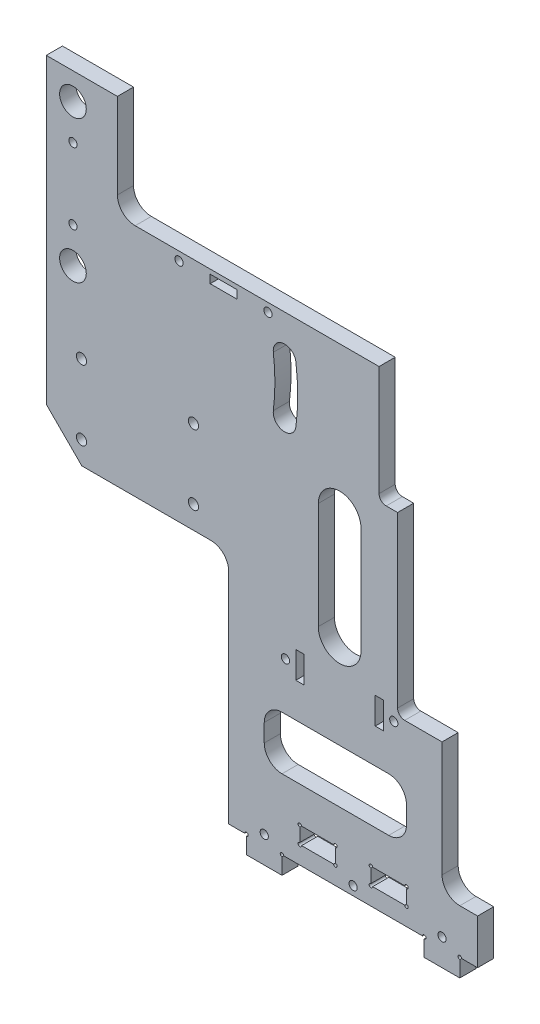
from build123d import *

# Parameters (mm, degrees)
SKETCH1_W                        = 12.7
SKETCH1_H                        = 6.0198
BOSS_EXTRUDE1_DEPTH              = 5.7658
SKETCH13_R                       = 0.635
CUT_EXTRUDE2_DEPTH               = 5.7658
CHAMFER1_SIZE                    = 50.8
F_4_CLEARANCE_HOLE1_D            = 2.9464
F_4_CLEARANCE_HOLE1_DEPTH        = 6.35
F_4_CLEARANCE_HOLE1_TIP          = 0.885187864
F_3_8_0_375_DIAMETER_HOLE1_D     = 9.525
F_3_8_0_375_DIAMETER_HOLE1_DEPTH = 6.35
F_3_8_0_375_DIAMETER_HOLE1_TIP   = 2.861598698
CUT_EXTRUDE3_REACH               = 234.708
FILLET3_R                        = 6.35
CUT_EXTRUDE4_REACH               = 234.708
CUT_EXTRUDE5_REACH               = 234.708
SKETCH26_W                       = 2.9591
SKETCH26_H                       = 9.525
CUT_EXTRUDE6_REACH               = 234.708
SKETCH29_W                       = 65.024
SKETCH29_H                       = 36.83
FILLET5_R                        = 6.35
SKETCH30_W                       = 65.151
SKETCH30_H                       = 50.8
BOSS_EXTRUDE2_DEPTH              = 5.7658
FILLET6_R                        = 6.35
CUT_EXTRUDE9_REACH               = 234.708
SKETCH32_W                       = 9.525
SKETCH32_H                       = 2.9591
F_6_CLEARANCE_HOLE1_D            = 3.6576
F_6_CLEARANCE_HOLE1_DEPTH        = 5.842
F_6_CLEARANCE_HOLE1_TIP          = 1.0988539
CUT_EXTRUDE10_REACH              = 234.708
CHAMFER3_SIZE                    = 12.7
CUT_EXTRUDE11_START              = -5.7658
CUT_EXTRUDE11_DEPTH              = 5.7658
CUT_EXTRUDE12_REACH              = 234.708
SKETCH36_W                       = 57.277
SKETCH36_H                       = 36.83
FILLET7_R                        = 2.54
FILLET8_R                        = 6.35
CUT_EXTRUDE13_REACH              = 234.708
SKETCH37_W                       = 9.525
SKETCH37_H                       = 2.9591
F_4_CLEARANCE_HOLE2_D            = 2.9464
F_4_CLEARANCE_HOLE2_DEPTH        = 5.7658
SKETCH38_W                       = 50.8
SKETCH38_H                       = 19.05
CUT_EXTRUDE14_DEPTH              = 233.70795425
FILLET9_R                        = 6.35


with BuildPart() as part:
    # Sketch1 → Boss-Extrude1 (new body)
    with BuildSketch(Plane.XY):
        Polygon((-25.4, 0), (25.4, 0), (25.4, -6.35), (38.1, -6.35), (38.1, 0), (44.45, 0), (44.45, 205.2008), (-109.601, 205.2008), (-109.601, 135.3508), (-44.45, 135.3508), (-44.45, 0), (-38.1, 0), (-38.1, -6.35), (-25.4, -6.35), align=None)
        with Locations((12.7, 9.3599)):
            Rectangle(SKETCH1_W, SKETCH1_H, mode=Mode.SUBTRACT)
        with Locations((-12.7, 9.3599)):
            Rectangle(SKETCH1_W, SKETCH1_H, mode=Mode.SUBTRACT)
    extrude(amount=BOSS_EXTRUDE1_DEPTH)

    # Sketch13 → Cut-Extrude2 (cut)
    with BuildSketch(Plane.XY):
        with Locations((-19.05, 12.3698)):
            Circle(SKETCH13_R)
    cut_extrude2 = extrude(amount=CUT_EXTRUDE2_DEPTH, mode=Mode.SUBTRACT)

    # Sketch-Pattern1: Cut-Extrude2 at 11 more places
    with Locations((12.7, 0, 0), (12.7, -6.0198, 0), (0, -6.0198, 0), (25.4, 0, 0), (38.1, 0, 0), (38.1, -6.0198, 0), (25.4, -6.0198, 0), (57.15, -12.3698, 0), (44.45, -12.3698, 0), (-6.35, -12.3698, 0), (-19.05, -12.3698, 0)):
        add(cut_extrude2, mode=Mode.SUBTRACT)

    # Chamfer1
    chamfer1_edges = [part.edges().sort_by_distance(p)[0] for p in [
        (44.45, 205.2008, 2.8829),
    ]]
    chamfer(chamfer1_edges, length=CHAMFER1_SIZE)

    # #4 Clearance Hole1
    with Locations(Plane.XY.offset(5.7658)):
        with Locations((-31.75, 3.175), (31.75, 3.175), (0, 3.175)):
            Hole(F_4_CLEARANCE_HOLE1_D / 2, depth=F_4_CLEARANCE_HOLE1_DEPTH)
            with Locations((0, 0, -(F_4_CLEARANCE_HOLE1_DEPTH + F_4_CLEARANCE_HOLE1_TIP / 2))):  # 118° drill point
                Cone(0, F_4_CLEARANCE_HOLE1_D / 2, F_4_CLEARANCE_HOLE1_TIP, mode=Mode.SUBTRACT)

    # 3/8 (0.375) Diameter Hole1
    with Locations(Plane.XY.offset(5.7658)):
        with Locations((-100.076, 144.8758), (-100.076, 195.6758)):
            Hole(F_3_8_0_375_DIAMETER_HOLE1_D / 2, depth=F_3_8_0_375_DIAMETER_HOLE1_DEPTH)
            with Locations((0, 0, -(F_3_8_0_375_DIAMETER_HOLE1_DEPTH + F_3_8_0_375_DIAMETER_HOLE1_TIP / 2))):  # 118° drill point
                Cone(0, F_3_8_0_375_DIAMETER_HOLE1_D / 2, F_3_8_0_375_DIAMETER_HOLE1_TIP, mode=Mode.SUBTRACT)

    # Sketch24 → Cut-Extrude3 (cut, up to next)
    with BuildSketch(Plane.XY.offset(5.7658), mode=Mode.PRIVATE) as cut_extrude3_sk1:
        Polygon((31.75, 167.1008), (31.75, 16.002), (44.45, 16.002), (44.45, 154.4008), align=None)
    cut_extrude3_tool1 = extrude(cut_extrude3_sk1.sketch, amount=-CUT_EXTRUDE3_REACH, mode=Mode.PRIVATE) & part.part
    add(cut_extrude3_tool1.solids().sort_by_distance((38.007144, 88.422828, 5.7658))[0], mode=Mode.SUBTRACT)

    # Fillet3
    fillet3_edges = [part.edges().sort_by_distance(p)[0] for p in [
        (31.75, 16.002, 2.8829),
    ]]
    fillet(fillet3_edges, radius=FILLET3_R)

    # Sketch25 → Cut-Extrude4 (cut, up to next)
    with BuildSketch(Plane.XY.offset(5.7658), mode=Mode.PRIVATE) as cut_extrude4_sk1:
        with BuildLine():
            ThreePointArc((-20.441531288, 134.8428), (-19.812, 144.8758), (-20.441531288, 154.9088))
            ThreePointArc((-20.441531288, 154.9088), (-24.981656286, 158.432924998), (-28.505781284, 153.8928))
            ThreePointArc((-28.505781284, 153.8928), (-27.94, 144.8758), (-28.505781284, 135.8588))
            ThreePointArc((-28.505781284, 135.8588), (-24.981656286, 131.318675002), (-20.441531288, 134.8428))
        make_face()
    cut_extrude4_tool1 = extrude(cut_extrude4_sk1.sketch, amount=-CUT_EXTRUDE4_REACH, mode=Mode.PRIVATE) & part.part
    # Sketch25 → Cut-Extrude4 (cut, up to next)
    with BuildSketch(Plane.XY.offset(5.7658), mode=Mode.PRIVATE) as cut_extrude4_sk2:
        with BuildLine():
            ThreePointArc((17.359640569, 130.0803), (18.288, 144.8758), (17.359640569, 159.6713))
            ThreePointArc((17.359640569, 159.6713), (12.819515571, 163.195424998), (9.295390572, 158.6553))
            ThreePointArc((9.295390572, 158.6553), (10.16, 144.8758), (9.295390572, 131.0963))
            ThreePointArc((9.295390572, 131.0963), (12.819515571, 126.556175002), (17.359640569, 130.0803))
        make_face()
    cut_extrude4_tool2 = extrude(cut_extrude4_sk2.sketch, amount=-CUT_EXTRUDE4_REACH, mode=Mode.PRIVATE) & part.part
    add(cut_extrude4_tool1.solids().sort_by_distance((-24.175106, 144.8758, 5.7658))[0], mode=Mode.SUBTRACT)
    add(cut_extrude4_tool2.solids().sort_by_distance((13.816141, 144.8758, 5.7658))[0], mode=Mode.SUBTRACT)

    # Sketch26 → Cut-Extrude5 (cut, up to next)
    with BuildSketch(Plane.XY.offset(5.7658), mode=Mode.PRIVATE) as cut_extrude5_sk1:
        with Locations((9.35355, 61.214)):
            Rectangle(SKETCH26_W, SKETCH26_H)
    cut_extrude5_tool1 = extrude(cut_extrude5_sk1.sketch, amount=-CUT_EXTRUDE5_REACH, mode=Mode.PRIVATE) & part.part
    # Sketch26 → Cut-Extrude5 (cut, up to next)
    with BuildSketch(Plane.XY.offset(5.7658), mode=Mode.PRIVATE) as cut_extrude5_sk2:
        with Locations((-19.00555, 61.214)):
            Rectangle(SKETCH26_W, SKETCH26_H)
    cut_extrude5_tool2 = extrude(cut_extrude5_sk2.sketch, amount=-CUT_EXTRUDE5_REACH, mode=Mode.PRIVATE) & part.part
    add(cut_extrude5_tool1.solids().sort_by_distance((9.35355, 61.214, 5.7658))[0], mode=Mode.SUBTRACT)
    add(cut_extrude5_tool2.solids().sort_by_distance((-19.00555, 61.214, 5.7658))[0], mode=Mode.SUBTRACT)

    # Sketch29 → Cut-Extrude6 (cut, up to next)
    with BuildSketch(Plane.XY.offset(5.7658), mode=Mode.PRIVATE) as cut_extrude6_sk1:
        with Locations((-0.762, 186.7858)):
            Rectangle(SKETCH29_W, SKETCH29_H)
    cut_extrude6_tool1 = extrude(cut_extrude6_sk1.sketch, amount=-CUT_EXTRUDE6_REACH, mode=Mode.PRIVATE) & part.part
    add(cut_extrude6_tool1.solids().sort_by_distance((-0.762, 186.7858, 5.7658))[0], mode=Mode.SUBTRACT)

    # Fillet5
    fillet5_edges = [part.edges().sort_by_distance(p)[0] for p in [
        (-33.274, 168.3708, 2.8829),
    ]]
    fillet(fillet5_edges, radius=FILLET5_R)

    # Sketch30 → Boss-Extrude2 (add)
    with BuildSketch(Plane.XY.offset(5.7658)):
        with Locations((-77.0255, 109.9508)):
            Rectangle(SKETCH30_W, SKETCH30_H)
    extrude(amount=-BOSS_EXTRUDE2_DEPTH)

    # Fillet6
    fillet6_edges = [part.edges().sort_by_distance(p)[0] for p in [
        (-44.45, 84.5508, 2.8829),
    ]]
    fillet(fillet6_edges, radius=FILLET6_R)

    # Sketch32 → Cut-Extrude9 (cut, up to next)
    with BuildSketch(Plane.XY.offset(5.7658), mode=Mode.PRIVATE) as cut_extrude9_sk1:
        with Locations((20.6375, 166.0975)):
            Rectangle(SKETCH32_W, SKETCH32_H)
    cut_extrude9_tool1 = extrude(cut_extrude9_sk1.sketch, amount=-CUT_EXTRUDE9_REACH, mode=Mode.PRIVATE) & part.part
    add(cut_extrude9_tool1.solids().sort_by_distance((20.6375, 166.0975, 5.7658))[0], mode=Mode.SUBTRACT)

    # #6 Clearance Hole1
    with Locations(Plane.XY.offset(5.7658)):
        with Locations((-97.0255, 117.65), (-57.0255, 117.65), (-97.0255, 92.65), (-57.0255, 92.65)):
            Hole(F_6_CLEARANCE_HOLE1_D / 2, depth=F_6_CLEARANCE_HOLE1_DEPTH)
            with Locations((0, 0, -(F_6_CLEARANCE_HOLE1_DEPTH + F_6_CLEARANCE_HOLE1_TIP / 2))):  # 118° drill point
                Cone(0, F_6_CLEARANCE_HOLE1_D / 2, F_6_CLEARANCE_HOLE1_TIP, mode=Mode.SUBTRACT)

    # Sketch31 → Cut-Extrude10 (cut, up to next)
    with BuildSketch(Plane.XY.offset(5.7658), mode=Mode.PRIVATE) as cut_extrude10_sk1:
        with BuildLine():
            Line((-12.446, 77.0763), (-12.446, 115.1763))
            ThreePointArc((-12.446, 115.1763), (-4.826, 122.7963), (2.794, 115.1763))
            Line((2.794, 115.1763), (2.794, 77.0763))
            ThreePointArc((2.794, 77.0763), (-4.826, 69.4563), (-12.446, 77.0763))
        make_face()
    cut_extrude10_tool1 = extrude(cut_extrude10_sk1.sketch, amount=-CUT_EXTRUDE10_REACH, mode=Mode.PRIVATE) & part.part
    add(cut_extrude10_tool1.solids().sort_by_distance((-4.826, 96.1263, 5.7658))[0], mode=Mode.SUBTRACT)

    # Chamfer3
    chamfer3_edges = [part.edges().sort_by_distance(p)[0] for p in [
        (-109.601, 84.5508, 2.8829),
    ]]
    chamfer(chamfer3_edges, length=CHAMFER3_SIZE)

    # Sketch35 → Cut-Extrude11 (cut)
    with BuildSketch(Plane.XY.offset(5.7658).offset(CUT_EXTRUDE11_START)):
        Polygon((31.75, 63.5), (15.875, 63.5), (15.875, 126.5243), (9.263515571, 126.5243), (9.263515571, 168.3708), (31.75, 168.3708), align=None)
    extrude(amount=CUT_EXTRUDE11_DEPTH, mode=Mode.SUBTRACT)

    # Sketch36 → Cut-Extrude12 (cut, up to next)
    with BuildSketch(Plane.XY.offset(5.7658), mode=Mode.PRIVATE) as cut_extrude12_sk1:
        with Locations((-55.5625, 186.7858)):
            Rectangle(SKETCH36_W, SKETCH36_H)
    cut_extrude12_tool1 = extrude(cut_extrude12_sk1.sketch, amount=-CUT_EXTRUDE12_REACH, mode=Mode.PRIVATE) & part.part
    add(cut_extrude12_tool1.solids().sort_by_distance((-55.5625, 186.7858, 5.7658))[0], mode=Mode.SUBTRACT)

    # Fillet7
    fillet7_edges = [part.edges().sort_by_distance(p)[0] for p in [
        (15.875, 63.5, 2.8829),
        (9.263515571, 126.5243, 2.8829),
    ]]
    fillet(fillet7_edges, radius=FILLET7_R)

    # Fillet8
    fillet8_edges = [part.edges().sort_by_distance(p)[0] for p in [
        (-84.201, 168.3708, 2.8829),
    ]]
    fillet(fillet8_edges, radius=FILLET8_R)

    # Sketch37 → Cut-Extrude13 (cut, up to next)
    with BuildSketch(Plane.XY.offset(5.7658), mode=Mode.PRIVATE) as cut_extrude13_sk1:
        with Locations((-46.298984429, 165.30375)):
            Rectangle(SKETCH37_W, SKETCH37_H)
    cut_extrude13_tool1 = extrude(cut_extrude13_sk1.sketch, amount=-CUT_EXTRUDE13_REACH, mode=Mode.PRIVATE) & part.part
    add(cut_extrude13_tool1.solids().sort_by_distance((-46.298984, 165.30375, 5.7658))[0], mode=Mode.SUBTRACT)

    # #4 Clearance Hole2
    with Locations(Plane.XY.offset(5.7658)):
        with Locations((-24.1681, 61.214), (14.5161, 61.214), (20.6375, 117.5708), (-100.076, 182.9758), (-100.076, 157.5758), (-62.173984429, 165.30375), (-30.423984429, 165.30375)):
            Hole(F_4_CLEARANCE_HOLE2_D / 2, depth=F_4_CLEARANCE_HOLE2_DEPTH)

    # Sketch38 → Cut-Extrude14 (cut, through all)
    with BuildSketch(Plane.XY.offset(5.7658)):
        with Locations((-6.35, 34.5948)):
            Rectangle(SKETCH38_W, SKETCH38_H)
    extrude(amount=-CUT_EXTRUDE14_DEPTH, mode=Mode.SUBTRACT)

    # Fillet9
    fillet9_edges = [part.edges().sort_by_distance(p)[0] for p in [
        (19.05, 44.1198, 2.8829),
        (19.05, 25.0698, 2.8829),
        (-31.75, 25.0698, 2.8829),
        (-31.75, 44.1198, 2.8829),
    ]]
    fillet(fillet9_edges, radius=FILLET9_R)


solid = part.part
